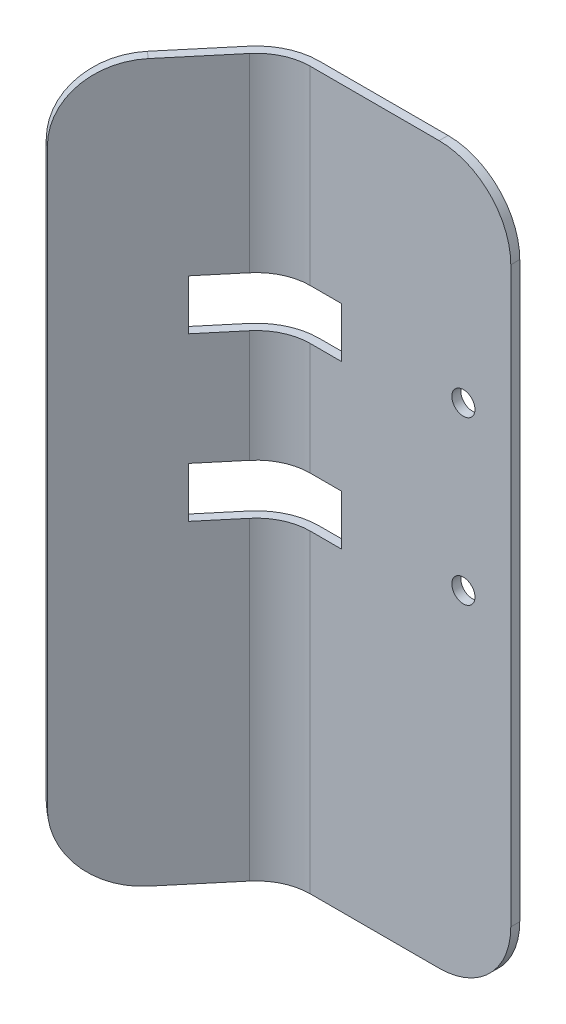
from build123d import *

# Parameters (mm, degrees)
BOSS_EXTRUDE1_DEPTH = 127
SKETCH2_R           = 2.049999964
SKETCH2_W           = 19.05
SKETCH2_H           = 8.89
CUT_EXTRUDE1_DEPTH  = 25.48749992
FILLET1_R           = 12.7
BOSS_EXTRUDE2_REACH = 18.672
SKETCH4_W           = 1.891908828
SKETCH4_H           = 8.89


with BuildPart() as part:
    # Sketch1 → Boss-Extrude1 (new body)
    with BuildSketch(Plane(origin=(0, 0, 0), x_dir=(1, 0, 0), z_dir=(0, 1, 0))):
        with BuildLine():
            Line((0, 0), (-35.56, 0))
            ThreePointArc((-35.56, 0), (-39.585438943, -0.892418328), (-42.856573321, -3.402448018))
            Line((-42.856573321, -3.402448018), (-59.216961931, -22.89999992))
            Line((-59.216961931, -22.89999992), (-60.433057484, -21.87957459))
            Line((-60.433057484, -21.87957459), (-44.072668874, -2.382022687))
            ThreePointArc((-44.072668874, -2.382022687), (-40.256345434, 0.546345283), (-35.56, 1.5875))
            Line((-35.56, 1.5875), (0, 1.5875))
            Line((0, 1.5875), (0, 0))
        make_face()
    extrude(amount=BOSS_EXTRUDE1_DEPTH)

    # Sketch2 → Cut-Extrude1 (cut, through all)
    with BuildSketch(Plane(origin=(0, 0, -1.5875), x_dir=(-1, 0, 0), z_dir=(0, 0, -1))):
        with Locations((8.399999964, 88.9)):
            Circle(SKETCH2_R)
        with Locations((8.399999964, 60.116067728)):
            Circle(SKETCH2_R)
        with Locations((39.514999964, 88.9)):
            Rectangle(SKETCH2_W, SKETCH2_H)
        with Locations((39.514999964, 60.116067728)):
            Rectangle(SKETCH2_W, SKETCH2_H)
    extrude(amount=-CUT_EXTRUDE1_DEPTH, mode=Mode.SUBTRACT)

    # Fillet1
    fillet1_edges = [part.edges().sort_by_distance(p)[0] for p in [
        (0, 0, -0.79375),
        (-59.825009707, 127, 22.389787255),
        (0, 127, -0.79375),
        (-59.825009707, 0, 22.389787255),
    ]]
    fillet(fillet1_edges, radius=FILLET1_R)

    # Boss-Extrude2: up to this face of the body (flat: up to its plane)
    boss_extrude2_end = Plane(part.part.faces().sort_by_distance((-49.039999964, 88.9, 9.536713147))[0])
    # Sketch4 → Boss-Extrude2 (add, up to the picked face)
    with BuildSketch(Plane(origin=(-23.473890996, 0, -19.696933277), x_dir=(0.64278761, 0, -0.766044443), z_dir=(0.766044443, 0, 0.64278761)), mode=Mode.PRIVATE) as boss_extrude2_sk1:
        with Locations((-38.827850468, 88.9)):
            Rectangle(SKETCH4_W, SKETCH4_H)
    boss_extrude2_tool1 = split(extrude(boss_extrude2_sk1.sketch, amount=-BOSS_EXTRUDE2_REACH, mode=Mode.PRIVATE), bisect_by=boss_extrude2_end, keep=Keep.BOTH, mode=Mode.PRIVATE)
    add(boss_extrude2_tool1.solids().sort_by_distance((-48.431952, 88.9, 10.046926))[0])
    # Sketch4 → Boss-Extrude2 (add, up to the picked face)
    with BuildSketch(Plane(origin=(-23.473890996, 0, -19.696933277), x_dir=(0.64278761, 0, -0.766044443), z_dir=(0.766044443, 0, 0.64278761)), mode=Mode.PRIVATE) as boss_extrude2_sk2:
        with Locations((-38.827850468, 60.116067728)):
            Rectangle(SKETCH4_W, SKETCH4_H)
    boss_extrude2_tool2 = split(extrude(boss_extrude2_sk2.sketch, amount=-BOSS_EXTRUDE2_REACH, mode=Mode.PRIVATE), bisect_by=boss_extrude2_end, keep=Keep.BOTH, mode=Mode.PRIVATE)
    add(boss_extrude2_tool2.solids().sort_by_distance((-48.431952, 60.116068, 10.046926))[0])


solid = part.part
